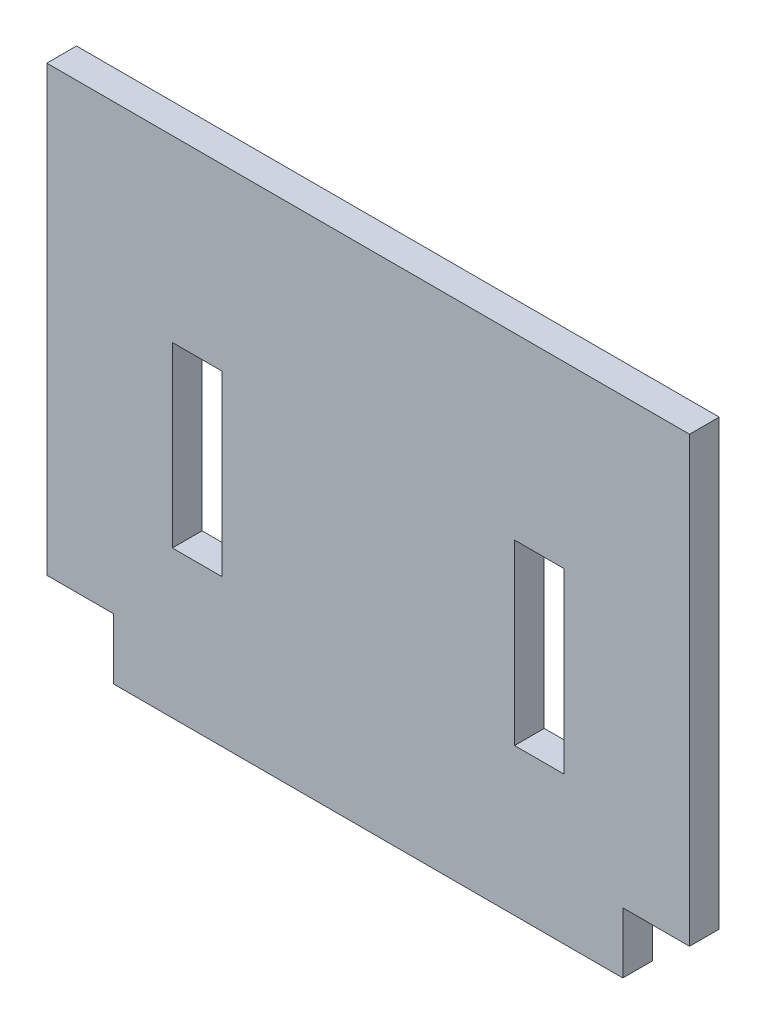
from build123d import *

# Parameters (mm, degrees)
SKETCH1_W           = 65
SKETCH1_H           = 51
BOSS_EXTRUDE1_DEPTH = 3
SKETCH3_W           = 6.75
SKETCH3_H           = 6.15
CUT_EXTRUDE1_DEPTH  = 4
SKETCH4_W           = 2.5
SKETCH4_H           = 9
CUT_EXTRUDE2_DEPTH  = 4


with BuildPart() as part:
    # Sketch1 → Boss-Extrude1 (new body)
    with BuildSketch(Plane.XY):
        with Locations((-744.213414634, 1009.240243902)):
            Rectangle(SKETCH1_W, SKETCH1_H)
    extrude(amount=BOSS_EXTRUDE1_DEPTH)

    # Sketch3 → Cut-Extrude1 (cut, through all)
    with BuildSketch(Plane.XY.offset(3)):
        with Locations((-773.338414634, 986.815243902)):
            Rectangle(SKETCH3_W, SKETCH3_H)
        with Locations((-715.088414634, 986.815243902)):
            Rectangle(SKETCH3_W, SKETCH3_H)
    extrude(amount=-CUT_EXTRUDE1_DEPTH, mode=Mode.SUBTRACT)

    # Sketch4 → Cut-Extrude2 (cut, through all)
    with BuildSketch(Plane.XY.offset(3)):
        Polygon((-761.516384975, 1007.624918562), (-761.516384975, 1016.624918562), (-764.016384975, 1016.624918562), (-764.016384975, 998.624918562), (-759.016384975, 998.624918562), (-759.016384975, 1007.624918562), align=None)
        with Locations((-760.266384975, 1012.124918562)):
            Rectangle(SKETCH4_W, SKETCH4_H)
        Polygon((-724.410444293, 1016.624918562), (-726.910444293, 1016.624918562), (-726.910444293, 1007.624918562), (-729.410444293, 1007.624918562), (-729.410444293, 998.624918562), (-724.410444293, 998.624918562), align=None)
        with Locations((-728.160444293, 1012.124918562)):
            Rectangle(SKETCH4_W, SKETCH4_H)
    extrude(amount=-CUT_EXTRUDE2_DEPTH, mode=Mode.SUBTRACT)


solid = part.part
